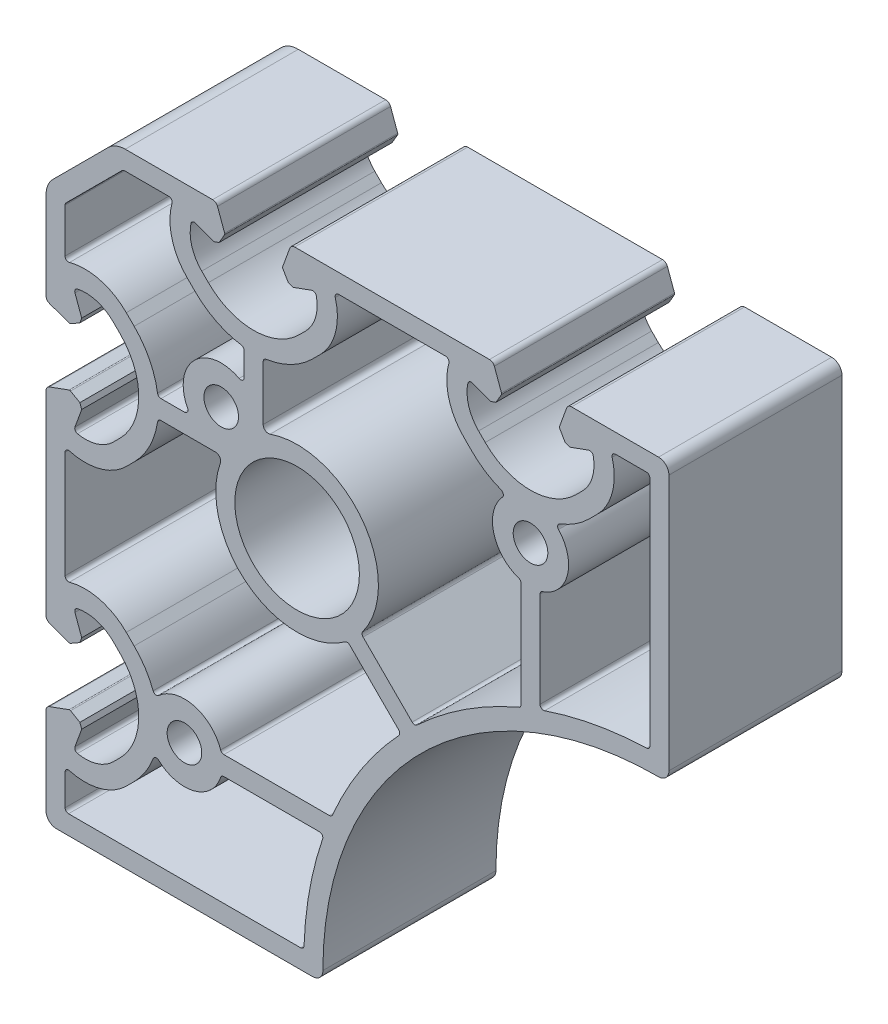
from build123d import *

# Parameters (mm, degrees)
SK_MAIN_EXTRUSION_R   = 2.5
SK_MAIN_EXTRUSION_R_2 = 9
MAIN_EXTRUSION_DEPTH  = 25


with BuildPart() as part:
    # Sk Main Extrusion → Main Extrusion (new body)
    with BuildSketch(Plane.XY):
        with BuildLine():
            Line((-12.203223816, 36.2764), (-24.826652532, 36.2764))
            ThreePointArc((-24.826652532, 36.2764), (-26.166044545, 36.009978364), (-27.301526266, 35.251273734))
            Line((-27.301526266, 35.251273734), (-35.251273734, 27.301526266))
            ThreePointArc((-35.251273734, 27.301526266), (-36.009978364, 26.166044545), (-36.2764, 24.826652532))
            Line((-36.2764, 24.826652532), (-36.2764, 12.203223816))
            ThreePointArc((-36.2764, 12.203223816), (-36.140764033, 11.773041489), (-35.782915107, 11.498454351))
            Line((-35.782915107, 11.498454351), (-32.947580212, 10.466476845))
            ThreePointArc((-32.947580212, 10.466476845), (-32.840286241, 10.452351325), (-32.737075177, 10.484893649))
            Line((-32.737075177, 10.484893649), (-31.387696024, 11.263958066))
            Line((-31.387696024, 11.263958066), (-31.121651581, 11.994909166))
            Line((-31.121651581, 11.994909166), (-32.09624631, 14.672586179))
            ThreePointArc((-32.09624631, 14.672586179), (-32.062889799, 15.087474612), (-31.727054467, 15.333360151))
            ThreePointArc((-31.727054467, 15.333360151), (-28.942282372, 15.209833013), (-26.549084887, 13.780560339))
            Line((-26.549084887, 13.780560339), (-25.585662274, 12.817137726))
            ThreePointArc((-25.585662274, 12.817137726), (-22.8764, 6.2764), (-25.585662274, -0.264337726))
            Line((-25.585662274, -0.264337726), (-26.549084887, -1.227760339))
            ThreePointArc((-26.549084887, -1.227760339), (-28.942282372, -2.657033013), (-31.727054467, -2.780560151))
            ThreePointArc((-31.727054467, -2.780560151), (-32.062889799, -2.534674612), (-32.09624631, -2.119786179))
            Line((-32.09624631, -2.119786179), (-31.121651581, 0.557890834))
            Line((-31.121651581, 0.557890834), (-31.387696024, 1.288841934))
            Line((-31.387696024, 1.288841934), (-32.737075177, 2.067906351))
            ThreePointArc((-32.737075177, 2.067906351), (-32.840286241, 2.100448675), (-32.947580212, 2.086323155))
            Line((-32.947580212, 2.086323155), (-35.782915107, 1.054345649))
            ThreePointArc((-35.782915107, 1.054345649), (-36.140764033, 0.779758511), (-36.2764, 0.349576184))
            Line((-36.2764, 0.349576184), (-36.2764, -27.796776184))
            ThreePointArc((-36.2764, -27.796776184), (-36.140764033, -28.226958511), (-35.782915107, -28.501545649))
            Line((-35.782915107, -28.501545649), (-32.947580212, -29.533523155))
            ThreePointArc((-32.947580212, -29.533523155), (-32.840286241, -29.547648675), (-32.737075177, -29.515106351))
            Line((-32.737075177, -29.515106351), (-31.387696024, -28.736041934))
            Line((-31.387696024, -28.736041934), (-31.121651581, -28.005090834))
            Line((-31.121651581, -28.005090834), (-32.09624631, -25.327413821))
            ThreePointArc((-32.09624631, -25.327413821), (-32.062889799, -24.912525388), (-31.727054467, -24.666639849))
            ThreePointArc((-31.727054467, -24.666639849), (-28.942282372, -24.790166987), (-26.549084887, -26.219439661))
            Line((-26.549084887, -26.219439661), (-25.585662274, -27.182862274))
            ThreePointArc((-25.585662274, -27.182862274), (-22.8764, -33.7236), (-25.585662274, -40.264337726))
            Line((-25.585662274, -40.264337726), (-26.549084887, -41.227760339))
            ThreePointArc((-26.549084887, -41.227760339), (-28.942282372, -42.657033013), (-31.727054467, -42.780560151))
            ThreePointArc((-31.727054467, -42.780560151), (-32.062889799, -42.534674612), (-32.09624631, -42.119786179))
            Line((-32.09624631, -42.119786179), (-31.121651581, -39.442109166))
            Line((-31.121651581, -39.442109166), (-31.387696024, -38.711158066))
            Line((-31.387696024, -38.711158066), (-32.737075177, -37.932093649))
            ThreePointArc((-32.737075177, -37.932093649), (-32.840286241, -37.899551325), (-32.947580212, -37.913676845))
            Line((-32.947580212, -37.913676845), (-35.782915107, -38.945654351))
            ThreePointArc((-35.782915107, -38.945654351), (-36.140764033, -39.220241489), (-36.2764, -39.650423816))
            Line((-36.2764, -39.650423816), (-36.2764, -52.2236))
            ThreePointArc((-36.2764, -52.2236), (-35.837060172, -53.284260172), (-34.7764, -53.7236))
            Line((-34.7764, -53.7236), (2.2236, -53.7236))
            ThreePointArc((2.2236, -53.7236), (3.284260172, -53.284260172), (3.7236, -52.2236))
            ThreePointArc((3.7236, -52.2236), (17.928921112, -17.928921112), (52.2236, -3.7236))
            ThreePointArc((52.2236, -3.7236), (53.284260172, -3.284260172), (53.7236, -2.2236))
            Line((53.7236, -2.2236), (53.7236, 34.7764))
            ThreePointArc((53.7236, 34.7764), (53.284260172, 35.837060172), (52.2236, 36.2764))
            Line((52.2236, 36.2764), (39.650423816, 36.2764))
            ThreePointArc((39.650423816, 36.2764), (39.220241489, 36.140764033), (38.945654351, 35.782915107))
            Line((38.945654351, 35.782915107), (37.913676845, 32.947580212))
            ThreePointArc((37.913676845, 32.947580212), (37.899551325, 32.840286241), (37.932093649, 32.737075177))
            Line((37.932093649, 32.737075177), (38.711158066, 31.387696024))
            Line((38.711158066, 31.387696024), (39.442109166, 31.121651581))
            Line((39.442109166, 31.121651581), (42.119786179, 32.09624631))
            ThreePointArc((42.119786179, 32.09624631), (42.534674612, 32.062889799), (42.780560151, 31.727054467))
            ThreePointArc((42.780560151, 31.727054467), (42.657033013, 28.942282372), (41.227760339, 26.549084887))
            Line((41.227760339, 26.549084887), (40.264337726, 25.585662274))
            ThreePointArc((40.264337726, 25.585662274), (33.7236, 22.8764), (27.182862274, 25.585662274))
            Line((27.182862274, 25.585662274), (26.219439661, 26.549084887))
            ThreePointArc((26.219439661, 26.549084887), (24.790166987, 28.942282372), (24.666639849, 31.727054467))
            ThreePointArc((24.666639849, 31.727054467), (24.912525388, 32.062889799), (25.327413821, 32.09624631))
            Line((25.327413821, 32.09624631), (28.005090834, 31.121651581))
            Line((28.005090834, 31.121651581), (28.736041934, 31.387696024))
            Line((28.736041934, 31.387696024), (29.515106351, 32.737075177))
            ThreePointArc((29.515106351, 32.737075177), (29.547648675, 32.840286241), (29.533523155, 32.947580212))
            Line((29.533523155, 32.947580212), (28.501545649, 35.782915107))
            ThreePointArc((28.501545649, 35.782915107), (28.226958511, 36.140764033), (27.796776184, 36.2764))
            Line((27.796776184, 36.2764), (-0.349576184, 36.2764))
            ThreePointArc((-0.349576184, 36.2764), (-0.779758511, 36.140764033), (-1.054345649, 35.782915107))
            Line((-1.054345649, 35.782915107), (-2.086323155, 32.947580212))
            ThreePointArc((-2.086323155, 32.947580212), (-2.100448675, 32.840286241), (-2.067906351, 32.737075177))
            Line((-2.067906351, 32.737075177), (-1.288841934, 31.387696024))
            Line((-1.288841934, 31.387696024), (-0.557890834, 31.121651581))
            Line((-0.557890834, 31.121651581), (2.119786179, 32.09624631))
            ThreePointArc((2.119786179, 32.09624631), (2.534674612, 32.062889799), (2.780560151, 31.727054467))
            ThreePointArc((2.780560151, 31.727054467), (2.657033013, 28.942282372), (1.227760339, 26.549084887))
            Line((1.227760339, 26.549084887), (0.264337726, 25.585662274))
            ThreePointArc((0.264337726, 25.585662274), (-6.2764, 22.8764), (-12.817137726, 25.585662274))
            Line((-12.817137726, 25.585662274), (-13.780560339, 26.549084887))
            ThreePointArc((-13.780560339, 26.549084887), (-15.209833013, 28.942282372), (-15.333360151, 31.727054467))
            ThreePointArc((-15.333360151, 31.727054467), (-15.087474612, 32.062889799), (-14.672586179, 32.09624631))
            Line((-14.672586179, 32.09624631), (-11.994909166, 31.121651581))
            Line((-11.994909166, 31.121651581), (-11.263958066, 31.387696024))
            Line((-11.263958066, 31.387696024), (-10.484893649, 32.737075177))
            ThreePointArc((-10.484893649, 32.737075177), (-10.452351325, 32.840286241), (-10.466476845, 32.947580212))
            Line((-10.466476845, 32.947580212), (-11.498454351, 35.782915107))
            ThreePointArc((-11.498454351, 35.782915107), (-11.773041489, 36.140764033), (-12.203223816, 36.2764))
        make_face()
        with Locations((-16.2764, -33.7236)):
            Circle(SK_MAIN_EXTRUSION_R, mode=Mode.SUBTRACT)
        with Locations((33.7236, 16.2764)):
            Circle(SK_MAIN_EXTRUSION_R, mode=Mode.SUBTRACT)
        Circle(SK_MAIN_EXTRUSION_R_2, mode=Mode.SUBTRACT)
        with Locations((-10.9602, 10.9602)):
            Circle(SK_MAIN_EXTRUSION_R, mode=Mode.SUBTRACT)
        with BuildLine():
            Line((43.344659284, 24.676896536), (42.208881374, 23.541118626))
            ThreePointArc((42.208881374, 23.541118626), (40.233571457, 21.945711947), (37.966796929, 20.801638095))
            ThreePointArc((37.966796929, 20.801638095), (37.657148802, 20.449561239), (37.775263735, 19.995811376))
            ThreePointArc((37.775263735, 19.995811376), (39.045537575, 14.888242788), (35.44235, 11.051852322))
            ThreePointArc((35.44235, 11.051852322), (35.193553706, 10.870044427), (35.0986, 10.576893442))
            Line((35.0986, 10.576893442), (35.0986, -3.216744612))
            ThreePointArc((35.0986, -3.216744612), (35.307321791, -3.623139746), (35.759228019, -3.6902408))
            ThreePointArc((35.759228019, -3.6902408), (43.026189707, -1.805645421), (50.490508213, -1.002911867))
            ThreePointArc((50.490508213, -1.002911867), (50.833081645, -0.850721859), (50.9736, -0.503197836))
            Line((50.9736, -0.503197836), (50.9736, 33.0264))
            ThreePointArc((50.9736, 33.0264), (50.827153391, 33.379953391), (50.4736, 33.5264))
            Line((50.4736, 33.5264), (45.998887467, 33.5264))
            ThreePointArc((45.998887467, 33.5264), (45.601190691, 33.329446654), (45.516804759, 32.893749097))
            ThreePointArc((45.516804759, 32.893749097), (45.538979867, 28.492354734), (43.344659284, 24.676896536))
        make_face(mode=Mode.SUBTRACT)
        with BuildLine():
            Line((21.448312533, 33.5264), (5.998887467, 33.5264))
            ThreePointArc((5.998887467, 33.5264), (5.601190691, 33.329446654), (5.516804759, 32.893749097))
            ThreePointArc((5.516804759, 32.893749097), (5.538979867, 28.492354734), (3.344659284, 24.676896536))
            Line((3.344659284, 24.676896536), (2.208881374, 23.541118626))
            ThreePointArc((2.208881374, 23.541118626), (-0.863352799, 21.316641833), (-4.4764, 20.16216804))
            ThreePointArc((-4.4764, 20.16216804), (-4.780543772, 19.993785162), (-4.9014, 19.667825042))
            Line((-4.9014, 19.667825042), (-4.9014, 11.790499482))
            ThreePointArc((-4.9014, 11.790499482), (-4.58480916, 11.178407577), (-3.902316, 11.083069513))
            ThreePointArc((-3.902316, 11.083069513), (9.433020572, 7.00575641), (9.48231304, -6.938893241))
            ThreePointArc((9.48231304, -6.938893241), (9.38729081, -7.272543823), (9.532262332, -7.587718684))
            Line((9.532262332, -7.587718684), (16.627122358, -14.68257871))
            ThreePointArc((16.627122358, -14.68257871), (16.971616291, -14.828943239), (17.321187094, -14.695156476))
            ThreePointArc((17.321187094, -14.695156476), (24.269690005, -9.268490688), (32.045459903, -5.11303683))
            ThreePointArc((32.045459903, -5.11303683), (32.265990675, -4.928712378), (32.3486, -4.653421579))
            Line((32.3486, -4.653421579), (32.3486, 10.576893442))
            ThreePointArc((32.3486, 10.576893442), (32.253646294, 10.870044427), (32.00485, 11.051852322))
            ThreePointArc((32.00485, 11.051852322), (28.401662425, 14.888242788), (29.671936265, 19.995811376))
            ThreePointArc((29.671936265, 19.995811376), (29.790051198, 20.449561239), (29.480403071, 20.801638095))
            ThreePointArc((29.480403071, 20.801638095), (27.213628543, 21.945711947), (25.238318626, 23.541118626))
            Line((25.238318626, 23.541118626), (24.102540716, 24.676896536))
            ThreePointArc((24.102540716, 24.676896536), (21.908220133, 28.492354734), (21.930395241, 32.893749097))
            ThreePointArc((21.930395241, 32.893749097), (21.846009309, 33.329446654), (21.448312533, 33.5264))
        make_face(mode=Mode.SUBTRACT)
        with BuildLine():
            Line((-14.761681374, 23.541118626), (-15.897459284, 24.676896536))
            ThreePointArc((-15.897459284, 24.676896536), (-18.091779867, 28.492354734), (-18.069604759, 32.893749097))
            ThreePointArc((-18.069604759, 32.893749097), (-18.153990691, 33.329446654), (-18.551687467, 33.5264))
            Line((-18.551687467, 33.5264), (-24.930205922, 33.5264))
            ThreePointArc((-24.930205922, 33.5264), (-25.121547638, 33.488339766), (-25.283759313, 33.379953391))
            Line((-25.283759313, 33.379953391), (-33.379953391, 25.283759313))
            ThreePointArc((-33.379953391, 25.283759313), (-33.488339766, 25.121547638), (-33.5264, 24.930205922))
            Line((-33.5264, 24.930205922), (-33.5264, 18.551687467))
            ThreePointArc((-33.5264, 18.551687467), (-33.329446654, 18.153990691), (-32.893749097, 18.069604759))
            ThreePointArc((-32.893749097, 18.069604759), (-28.492354734, 18.091779867), (-24.676896536, 15.897459284))
            Line((-24.676896536, 15.897459284), (-23.541118626, 14.761681374))
            ThreePointArc((-23.541118626, 14.761681374), (-21.316641833, 11.689447201), (-20.16216804, 8.0764))
            ThreePointArc((-20.16216804, 8.0764), (-19.993785162, 7.772256228), (-19.667825042, 7.6514))
            Line((-19.667825042, 7.6514), (-16.262147054, 7.6514))
            ThreePointArc((-16.262147054, 7.6514), (-15.833758601, 7.893556378), (-15.820318133, 8.385466667))
            ThreePointArc((-15.820318133, 8.385466667), (-14.849287297, 14.849287297), (-8.385466667, 15.820318133))
            ThreePointArc((-8.385466667, 15.820318133), (-7.893556378, 15.833758601), (-7.6514, 16.262147054))
            Line((-7.6514, 16.262147054), (-7.6514, 19.667825042))
            ThreePointArc((-7.6514, 19.667825042), (-7.772256228, 19.993785162), (-8.0764, 20.16216804))
            ThreePointArc((-8.0764, 20.16216804), (-11.689447201, 21.316641833), (-14.761681374, 23.541118626))
        make_face(mode=Mode.SUBTRACT)
        with BuildLine():
            Line((-23.541118626, -2.208881374), (-24.676896536, -3.344659284))
            ThreePointArc((-24.676896536, -3.344659284), (-28.492354734, -5.538979867), (-32.893749097, -5.516804759))
            ThreePointArc((-32.893749097, -5.516804759), (-33.329446654, -5.601190691), (-33.5264, -5.998887467))
            Line((-33.5264, -5.998887467), (-33.5264, -21.448312533))
            ThreePointArc((-33.5264, -21.448312533), (-33.329446654, -21.846009309), (-32.893749097, -21.930395241))
            ThreePointArc((-32.893749097, -21.930395241), (-28.492354734, -21.908220133), (-24.676896536, -24.102540716))
            Line((-24.676896536, -24.102540716), (-23.541118626, -25.238318626))
            ThreePointArc((-23.541118626, -25.238318626), (-21.945711947, -27.213628543), (-20.801638095, -29.480403071))
            ThreePointArc((-20.801638095, -29.480403071), (-20.449561239, -29.790051198), (-19.995811376, -29.671936265))
            ThreePointArc((-19.995811376, -29.671936265), (-14.888242788, -28.401662425), (-11.051852322, -32.00485))
            ThreePointArc((-11.051852322, -32.00485), (-10.870044427, -32.253646294), (-10.576893442, -32.3486))
            Line((-10.576893442, -32.3486), (4.653421579, -32.3486))
            ThreePointArc((4.653421579, -32.3486), (4.928712378, -32.265990675), (5.11303683, -32.045459903))
            ThreePointArc((5.11303683, -32.045459903), (9.268490688, -24.269690005), (14.695156476, -17.321187094))
            ThreePointArc((14.695156476, -17.321187094), (14.828943239, -16.971616291), (14.68257871, -16.627122358))
            Line((14.68257871, -16.627122358), (7.587718684, -9.532262332))
            ThreePointArc((7.587718684, -9.532262332), (7.272543823, -9.38729081), (6.938893241, -9.48231304))
            ThreePointArc((6.938893241, -9.48231304), (-7.00575641, -9.433020572), (-11.083069513, 3.902316))
            ThreePointArc((-11.083069513, 3.902316), (-11.178407577, 4.58480916), (-11.790499482, 4.9014))
            Line((-11.790499482, 4.9014), (-19.667825042, 4.9014))
            ThreePointArc((-19.667825042, 4.9014), (-19.993785162, 4.780543772), (-20.16216804, 4.4764))
            ThreePointArc((-20.16216804, 4.4764), (-21.316641833, 0.863352799), (-23.541118626, -2.208881374))
        make_face(mode=Mode.SUBTRACT)
        with BuildLine():
            Line((-23.541118626, -42.208881374), (-24.676896536, -43.344659284))
            ThreePointArc((-24.676896536, -43.344659284), (-28.492354734, -45.538979867), (-32.893749097, -45.516804759))
            ThreePointArc((-32.893749097, -45.516804759), (-33.329446654, -45.601190691), (-33.5264, -45.998887467))
            Line((-33.5264, -45.998887467), (-33.5264, -50.4736))
            ThreePointArc((-33.5264, -50.4736), (-33.379953391, -50.827153391), (-33.0264, -50.9736))
            Line((-33.0264, -50.9736), (0.503197836, -50.9736))
            ThreePointArc((0.503197836, -50.9736), (0.850721859, -50.833081645), (1.002911867, -50.490508213))
            ThreePointArc((1.002911867, -50.490508213), (1.805645421, -43.026189707), (3.6902408, -35.759228019))
            ThreePointArc((3.6902408, -35.759228019), (3.623139746, -35.307321791), (3.216744612, -35.0986))
            Line((3.216744612, -35.0986), (-10.576893442, -35.0986))
            ThreePointArc((-10.576893442, -35.0986), (-10.870044427, -35.193553706), (-11.051852322, -35.44235))
            ThreePointArc((-11.051852322, -35.44235), (-14.888242788, -39.045537575), (-19.995811376, -37.775263735))
            ThreePointArc((-19.995811376, -37.775263735), (-20.449561239, -37.657148802), (-20.801638095, -37.966796929))
            ThreePointArc((-20.801638095, -37.966796929), (-21.945711947, -40.233571457), (-23.541118626, -42.208881374))
        make_face(mode=Mode.SUBTRACT)
    extrude(amount=-MAIN_EXTRUSION_DEPTH)


solid = part.part
